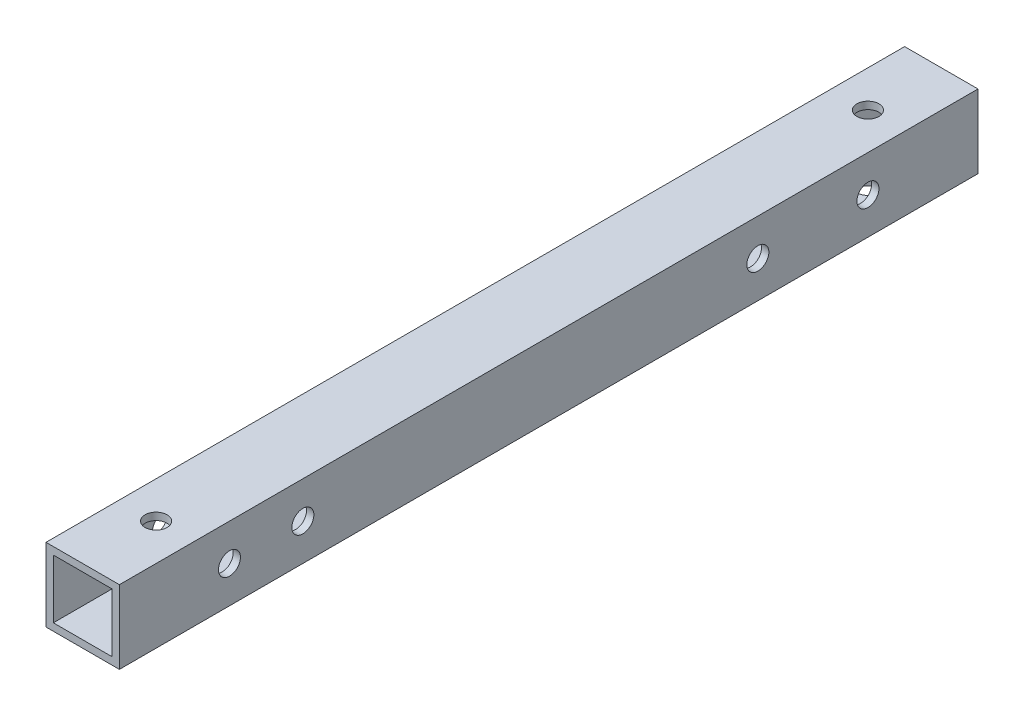
from build123d import *

# Parameters (mm, degrees)
SKETCH_1_W          = 10
SKETCH_1_H          = 10
SKETCH_1_W_2        = 8
SKETCH_1_H_2        = 8
EXTRUDE_1_DEPTH     = 117
SKETCH_2_R          = 1.5
CUT_EXTRUDE_1_DEPTH = 11
SKETCH_3_R          = 1.5
CUT_EXTRUDE_2_DEPTH = 10


with BuildPart() as part:
    # 草图1 → 拉伸-薄壁1 (new body)
    with BuildSketch(Plane.XY):
        Rectangle(SKETCH_1_W, SKETCH_1_H)
        Rectangle(SKETCH_1_W_2, SKETCH_1_H_2, mode=Mode.SUBTRACT)
    extrude(amount=EXTRUDE_1_DEPTH)

    # 草图2 → 切除-拉伸1 (cut, through all)
    with BuildSketch(Plane(origin=(0, 5, 0), x_dir=(1, 0, 0), z_dir=(0, 1, 0))):
        with Locations((0, -10)):
            Circle(SKETCH_2_R)
        with Locations((0, -107)):
            Circle(SKETCH_2_R)
    extrude(amount=-CUT_EXTRUDE_1_DEPTH, mode=Mode.SUBTRACT)

    # 草图3 → 切除-拉伸2 (cut)
    with BuildSketch(Plane(origin=(5, 0, 0), x_dir=(0, 0, -1), z_dir=(1, 0, 0))):
        with Locations((-15, 0)):
            Circle(SKETCH_3_R)
        with Locations((-30, 0)):
            Circle(SKETCH_3_R)
        with Locations((-102, 0)):
            Circle(SKETCH_3_R)
        with Locations((-92, 0)):
            Circle(SKETCH_3_R)
    extrude(amount=-CUT_EXTRUDE_2_DEPTH, mode=Mode.SUBTRACT)


solid = part.part
